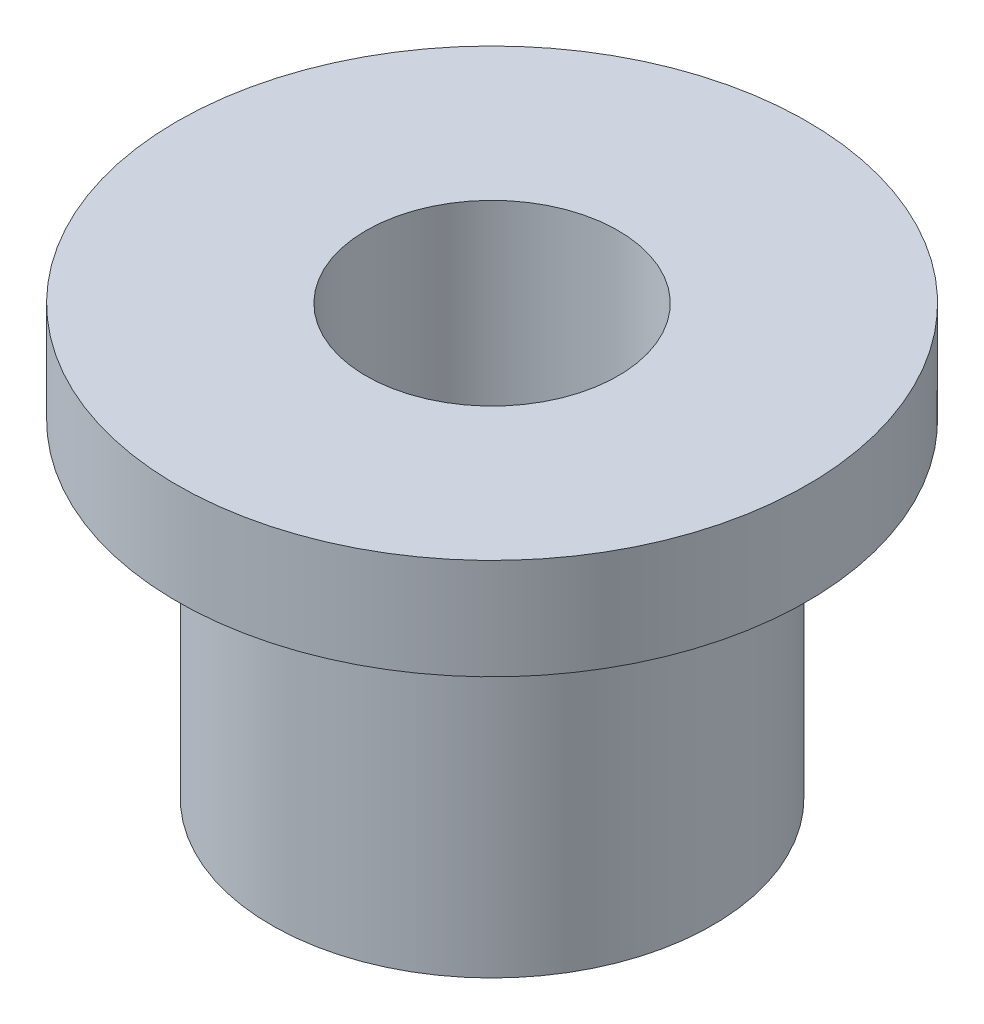
from build123d import *

# Parameters (mm, degrees)
CUT_EXTRUDE1_REACH = 36
SKETCH2_R          = 10


with BuildPart() as part:
    # Sketch1 → Revolve1 (revolve)
    with BuildSketch(Plane.XY):
        Polygon((0, 0), (17.5, 0), (17.5, 26), (25, 26), (25, 34), (0, 34), align=None)
    revolve(axis=Axis((0, 34.030960003, 0), (0, -1, 0)))

    # Sketch2 → Cut-Extrude1 (cut, up to next)
    with BuildSketch(Plane(origin=(0, 34, 0), x_dir=(1, 0, 0), z_dir=(0, 1, 0)), mode=Mode.PRIVATE) as cut_extrude1_sk1:
        Circle(SKETCH2_R)
    cut_extrude1_tool1 = extrude(cut_extrude1_sk1.sketch, amount=-CUT_EXTRUDE1_REACH, mode=Mode.PRIVATE) & part.part
    add(cut_extrude1_tool1.solids().sort_by_distance((0, 34, 0))[0], mode=Mode.SUBTRACT)


solid = part.part
